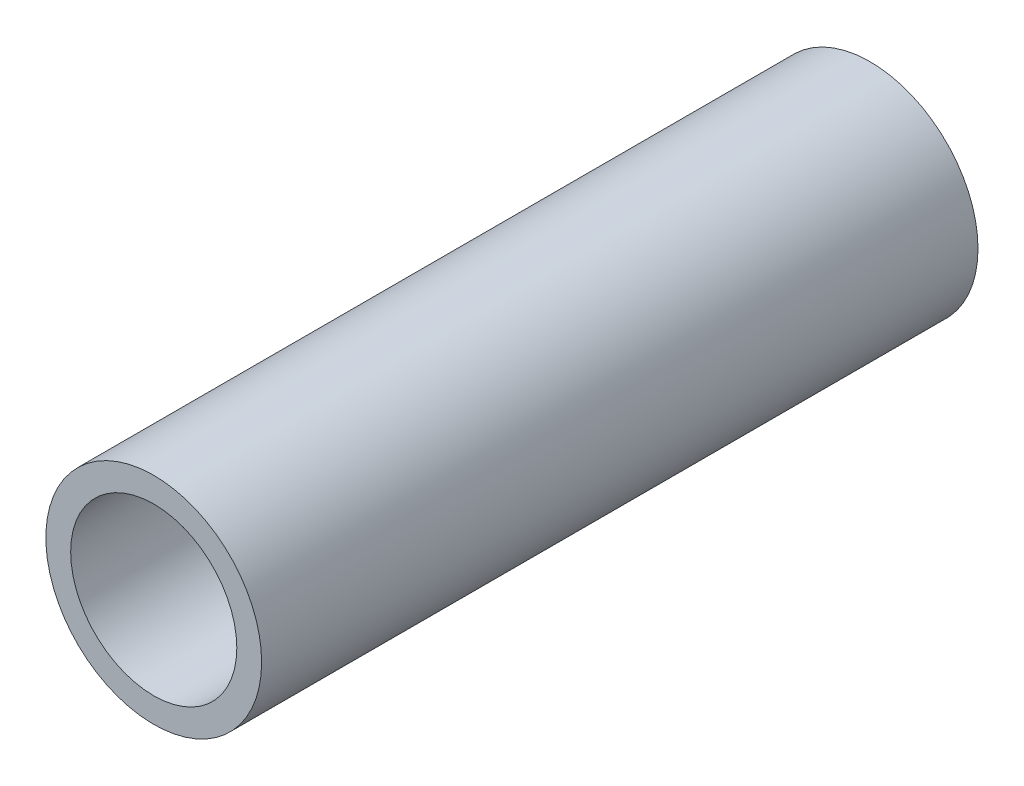
from build123d import *

# Parameters (mm, degrees)
SKETCH1_R           = 6.35
SKETCH1_R_2         = 4.8895
BOSS_EXTRUDE1_DEPTH = 42.164


with BuildPart() as part:
    # Sketch1 → Boss-Extrude1 (new body)
    with BuildSketch(Plane.XY):
        Circle(SKETCH1_R)
        Circle(SKETCH1_R_2, mode=Mode.SUBTRACT)
    extrude(amount=BOSS_EXTRUDE1_DEPTH)


solid = part.part
